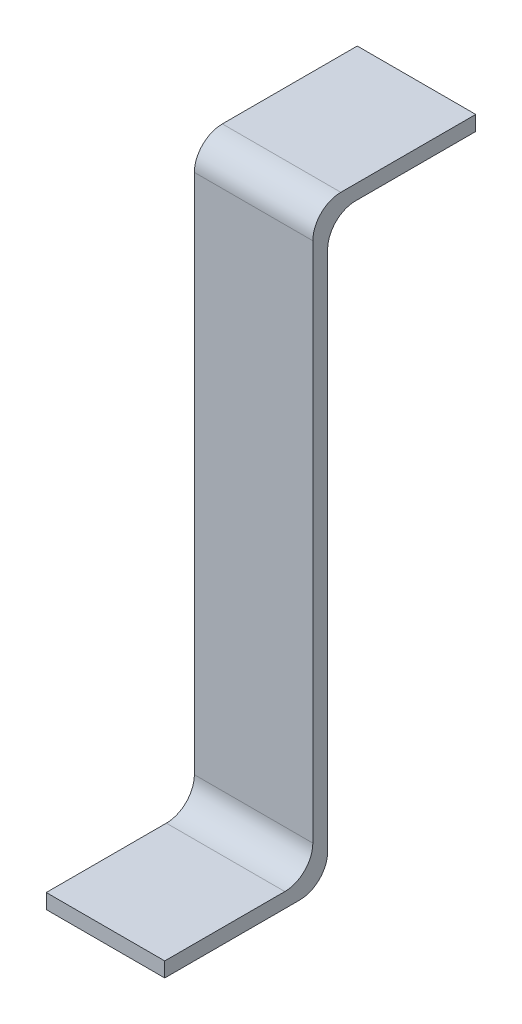
from build123d import *

# Parameters (mm, degrees)
BOSS_EXTRUDE1_DEPTH = 12.7


with BuildPart() as part:
    # Sketch1 → Boss-Extrude1 (new body)
    with BuildSketch(Plane(origin=(0, 0, 0), x_dir=(0, 0, -1), z_dir=(1, 0, 0))):
        with BuildLine():
            Line((1.4125, 63.5), (15.875, 63.5))
            Line((15.875, 63.5), (15.875, 61.9125))
            Line((15.875, 61.9125), (3, 61.9125))
            ThreePointArc((3, 61.9125), (0.878679656, 61.033820344), (0, 58.9125))
            Line((0, 58.9125), (0, 3))
            ThreePointArc((0, 3), (-0.878679656, 0.878679656), (-3, 0))
            Line((-3, 0), (-17.4625, 0))
            Line((-17.4625, 0), (-17.4625, 1.5875))
            Line((-17.4625, 1.5875), (-4.5875, 1.5875))
            ThreePointArc((-4.5875, 1.5875), (-2.466179656, 2.466179656), (-1.5875, 4.5875))
            Line((-1.5875, 4.5875), (-1.5875, 60.5))
            ThreePointArc((-1.5875, 60.5), (-0.708820344, 62.621320344), (1.4125, 63.5))
        make_face()
    extrude(amount=BOSS_EXTRUDE1_DEPTH)


solid = part.part
